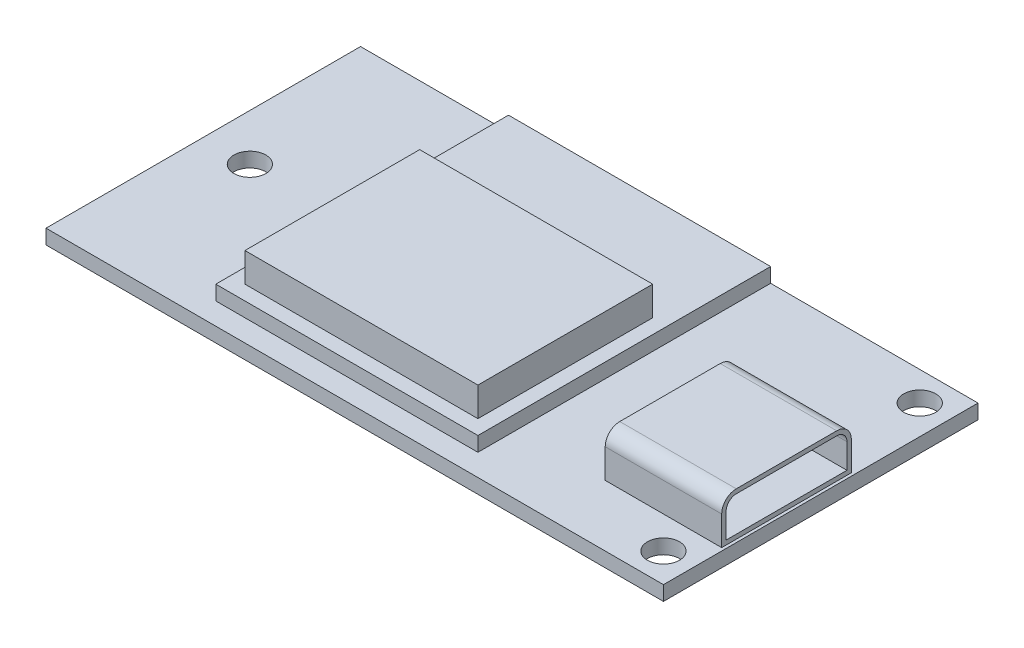
from build123d import *

# Parameters (mm, degrees)
SKETCH_1_W            = 42.4
SKETCH_1_H            = 21.6
SKETCH_1_R            = 1.1
EXTRUDE_1_DEPTH       = 1
SKETCH_2_W            = 18
SKETCH_2_H            = 14
SKETCH_2_W_2          = 8
SKETCH_2_H_2          = 8.9
EXTRUDE_2_DEPTH       = 3
FILLET_1_R            = 1
SKETCH_2_3_W          = 18
SKETCH_2_3_H          = 6.1
EXTRUDE_3_DEPTH       = 1
CUT_EXTRUDE_1_DEPTH   = 7.7
SKETCH_4_W            = 18
SKETCH_4_H            = 14
SKETCH_4_W_2          = 16
SKETCH_4_H_2          = 12
CUT_EXTRUDE_1_2_DEPTH = 2


with BuildPart() as part:
    # Sketch 1 → Extrude 1 (new body)
    with BuildSketch(Plane(origin=(0, 0, 0), x_dir=(1, 0, 0), z_dir=(0, 1, 0))):
        Rectangle(SKETCH_1_W, SKETCH_1_H)
        with Locations((-18, 0)):
            Circle(SKETCH_1_R, mode=Mode.SUBTRACT)
        with Locations((19.2, 8.8)):
            Circle(SKETCH_1_R, mode=Mode.SUBTRACT)
        with Locations((19.2, -8.8)):
            Circle(SKETCH_1_R, mode=Mode.SUBTRACT)
    extrude(amount=EXTRUDE_1_DEPTH)

    # Sketch 2 → Extrude 2 (add)
    with BuildSketch(Plane(origin=(0, 1, 0), x_dir=(1, 0, 0), z_dir=(0, 1, 0))):
        with Locations((-2.04, -2.3)):
            Rectangle(SKETCH_2_W, SKETCH_2_H)
        with Locations((17, -2.15)):
            Rectangle(SKETCH_2_W_2, SKETCH_2_H_2)
    extrude(amount=EXTRUDE_2_DEPTH)

    # Fillet 1
    fillet_1_edges = [part.edges().sort_by_distance(p)[0] for p in [
        (17, 4, -2.3),
        (17, 4, 6.6),
    ]]
    fillet(fillet_1_edges, radius=FILLET_1_R)

    # Sketch 2_3 → Extrude 3 (add)
    with BuildSketch(Plane(origin=(0, 1, 0), x_dir=(1, 0, 0), z_dir=(0, 1, 0))):
        with Locations((-2.04, 7.75)):
            Rectangle(SKETCH_2_3_W, SKETCH_2_3_H)
    extrude(amount=EXTRUDE_3_DEPTH)

    # Sketch 3 → Cut-Extrude 1 (cut)
    with BuildSketch(Plane(origin=(21, 0, 0), x_dir=(0, 0, -1), z_dir=(1, 0, 0))):
        with BuildLine():
            Line((1.3, 3.7), (-5.6, 3.7))
            ThreePointArc((-5.6, 3.7), (-6.094974747, 3.494974747), (-6.3, 3))
            Line((-6.3, 3), (-6.3, 1.3))
            Line((-6.3, 1.3), (2, 1.3))
            Line((2, 1.3), (2, 3))
            ThreePointArc((2, 3), (1.794974747, 3.494974747), (1.3, 3.7))
        make_face()
    extrude(amount=-CUT_EXTRUDE_1_DEPTH, mode=Mode.SUBTRACT)

    # Sketch 4 → Cut-Extrude 1 2 (cut)
    with BuildSketch(Plane(origin=(0, 4, 0), x_dir=(1, 0, 0), z_dir=(0, 1, 0))):
        with Locations((-2.04, -2.3)):
            Rectangle(SKETCH_4_W, SKETCH_4_H)
        with Locations((-2.04, -2.3)):
            Rectangle(SKETCH_4_W_2, SKETCH_4_H_2, mode=Mode.SUBTRACT)
    extrude(amount=-CUT_EXTRUDE_1_2_DEPTH, mode=Mode.SUBTRACT)


solid = part.part
